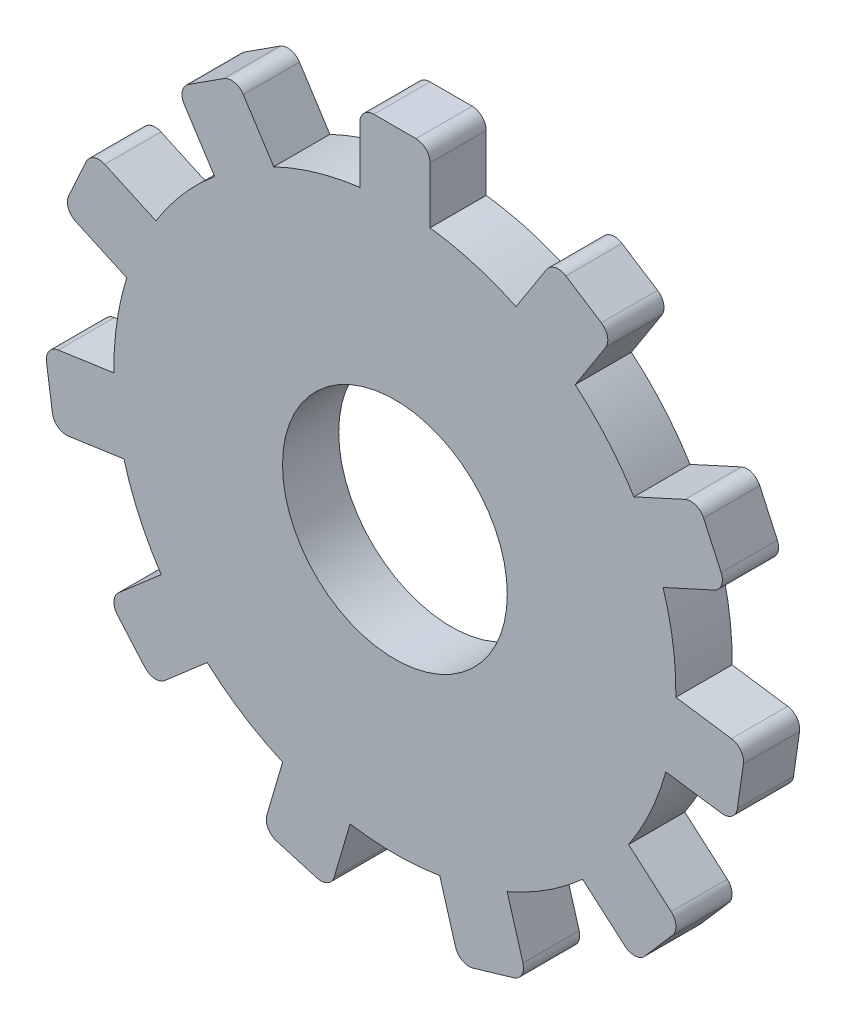
from build123d import *

# Parameters (mm, degrees)
SKETCH1_R           = 20.32
BOSS_EXTRUDE3_DEPTH = 10.16


with BuildPart() as part:
    # Sketch1 → Boss-Extrude3 (new body)
    with BuildSketch(Plane.XY):
        with BuildLine():
            Line((37.321963159, 51.023310491), (30.908331921, 55.145101009))
            ThreePointArc((30.908331921, 55.145101009), (28.995188409, 55.490270076), (27.398320271, 54.381544712))
            Line((27.398320271, 54.381544712), (21.905409565, 45.834408819))
            ThreePointArc((21.905409565, 45.834408819), (14.312013888, 48.74224306), (6.351949066, 50.401316878))
            Line((6.351949066, 50.401316878), (6.351949066, 60.561316878))
            ThreePointArc((6.351949066, 60.561316878), (5.608000291, 62.357368102), (3.811949066, 63.101316878))
            Line((3.811949066, 63.101316878), (-3.811949066, 63.101316878))
            ThreePointArc((-3.811949066, 63.101316878), (-5.608000291, 62.357368102), (-6.351949066, 60.561316878))
            Line((-6.351949066, 60.561316878), (-6.351949066, 50.401316878))
            ThreePointArc((-6.351949066, 50.401316878), (-14.312013888, 48.74224306), (-21.905409565, 45.834408819))
            Line((-21.905409565, 45.834408819), (-27.398320271, 54.381544712))
            ThreePointArc((-27.398320271, 54.381544712), (-28.995188409, 55.490270076), (-30.908331921, 55.145101009))
            Line((-30.908331921, 55.145101009), (-37.321963159, 51.023310491))
            ThreePointArc((-37.321963159, 51.023310491), (-38.430688522, 49.426442353), (-38.085519456, 47.513298841))
            Line((-38.085519456, 47.513298841), (-32.59260875, 38.966162948))
            ThreePointArc((-32.59260875, 38.966162948), (-38.392078377, 33.266925284), (-43.207955436, 26.71539981))
            Line((-43.207955436, 26.71539981), (-52.449816509, 30.936016342))
            ThreePointArc((-52.449816509, 30.936016342), (-54.392609658, 31.005403375), (-55.81543591, 29.680705207))
            Line((-55.81543591, 29.680705207), (-58.982517652, 22.745763536))
            ThreePointArc((-58.982517652, 22.745763536), (-59.051904686, 20.802970387), (-57.727206517, 19.380144135))
            Line((-57.727206517, 19.380144135), (-48.485345444, 15.159527603))
            ThreePointArc((-48.485345444, 15.159527603), (-50.282929248, 7.229593784), (-50.792280749, -0.885559877))
            Line((-50.792280749, -0.885559877), (-60.848866599, -2.331478634))
            ThreePointArc((-60.848866599, -2.331478634), (-62.520761661, -3.323459823), (-63.001533372, -5.207104785))
            Line((-63.001533372, -5.207104785), (-61.916539542, -12.753402628))
            ThreePointArc((-61.916539542, -12.753402628), (-60.924558353, -14.42529769), (-59.040913391, -14.906069401))
            Line((-59.040913391, -14.906069401), (-48.984327541, -13.460150644))
            ThreePointArc((-48.984327541, -13.460150644), (-46.209305364, -21.10308266), (-42.250415805, -28.20536056))
            Line((-42.250415805, -28.20536056), (-49.928831481, -34.858745616))
            ThreePointArc((-49.928831481, -34.858745616), (-50.799013587, -36.59714801), (-50.185089135, -38.441695799))
            Line((-50.185089135, -38.441695799), (-45.192497609, -44.203453568))
            ThreePointArc((-45.192497609, -44.203453568), (-43.454095215, -45.073635675), (-41.609547426, -44.459711223))
            Line((-41.609547426, -44.459711223), (-33.93113175, -37.806326166))
            ThreePointArc((-33.93113175, -37.806326166), (-27.464553527, -42.735679468), (-20.29434237, -46.570158554))
            Line((-20.29434237, -46.570158554), (-23.156745148, -56.318607166))
            ThreePointArc((-23.156745148, -56.318607166), (-22.948937628, -58.251500287), (-21.435233689, -59.471320013))
            Line((-21.435233689, -59.471320013), (-14.120156999, -61.619220327))
            ThreePointArc((-14.120156999, -61.619220327), (-12.187263879, -61.411412808), (-10.967444152, -59.897708869))
            Line((-10.967444152, -59.897708869), (-8.105041374, -50.149260257))
            ThreePointArc((-8.105041374, -50.149260257), (0, -50.8), (8.105041374, -50.149260257))
            Line((8.105041374, -50.149260257), (10.967444152, -59.897708869))
            ThreePointArc((10.967444152, -59.897708869), (12.187263879, -61.411412808), (14.120156999, -61.619220327))
            Line((14.120156999, -61.619220327), (21.435233689, -59.471320013))
            ThreePointArc((21.435233689, -59.471320013), (22.948937628, -58.251500287), (23.156745148, -56.318607166))
            Line((23.156745148, -56.318607166), (20.29434237, -46.570158554))
            ThreePointArc((20.29434237, -46.570158554), (27.464553527, -42.735679468), (33.93113175, -37.806326166))
            Line((33.93113175, -37.806326166), (41.609547426, -44.459711223))
            ThreePointArc((41.609547426, -44.459711223), (43.454095215, -45.073635675), (45.192497609, -44.203453568))
            Line((45.192497609, -44.203453568), (50.185089135, -38.441695799))
            ThreePointArc((50.185089135, -38.441695799), (50.799013587, -36.59714801), (49.928831481, -34.858745616))
            Line((49.928831481, -34.858745616), (42.250415805, -28.205360559))
            ThreePointArc((42.250415805, -28.205360559), (46.209305364, -21.10308266), (48.984327541, -13.460150644))
            Line((48.984327541, -13.460150644), (59.040913391, -14.906069401))
            ThreePointArc((59.040913391, -14.906069401), (60.924558353, -14.42529769), (61.916539542, -12.753402628))
            Line((61.916539542, -12.753402628), (63.001533372, -5.207104785))
            ThreePointArc((63.001533372, -5.207104785), (62.520761661, -3.323459823), (60.848866599, -2.331478634))
            Line((60.848866599, -2.331478634), (50.792280749, -0.885559877))
            ThreePointArc((50.792280749, -0.885559877), (50.282929248, 7.229593784), (48.485345444, 15.159527603))
            Line((48.485345444, 15.159527603), (57.727206517, 19.380144135))
            ThreePointArc((57.727206517, 19.380144135), (59.051904686, 20.802970387), (58.982517652, 22.745763536))
            Line((58.982517652, 22.745763536), (55.81543591, 29.680705207))
            ThreePointArc((55.81543591, 29.680705207), (54.392609658, 31.005403375), (52.449816509, 30.936016342))
            Line((52.449816509, 30.936016342), (43.207955436, 26.71539981))
            ThreePointArc((43.207955436, 26.71539981), (38.392078377, 33.266925284), (32.59260875, 38.966162948))
            Line((32.59260875, 38.966162948), (38.085519456, 47.513298841))
            ThreePointArc((38.085519456, 47.513298841), (38.430688522, 49.426442353), (37.321963159, 51.023310491))
        make_face()
        Circle(SKETCH1_R, mode=Mode.SUBTRACT)
    extrude(amount=BOSS_EXTRUDE3_DEPTH)


solid = part.part
